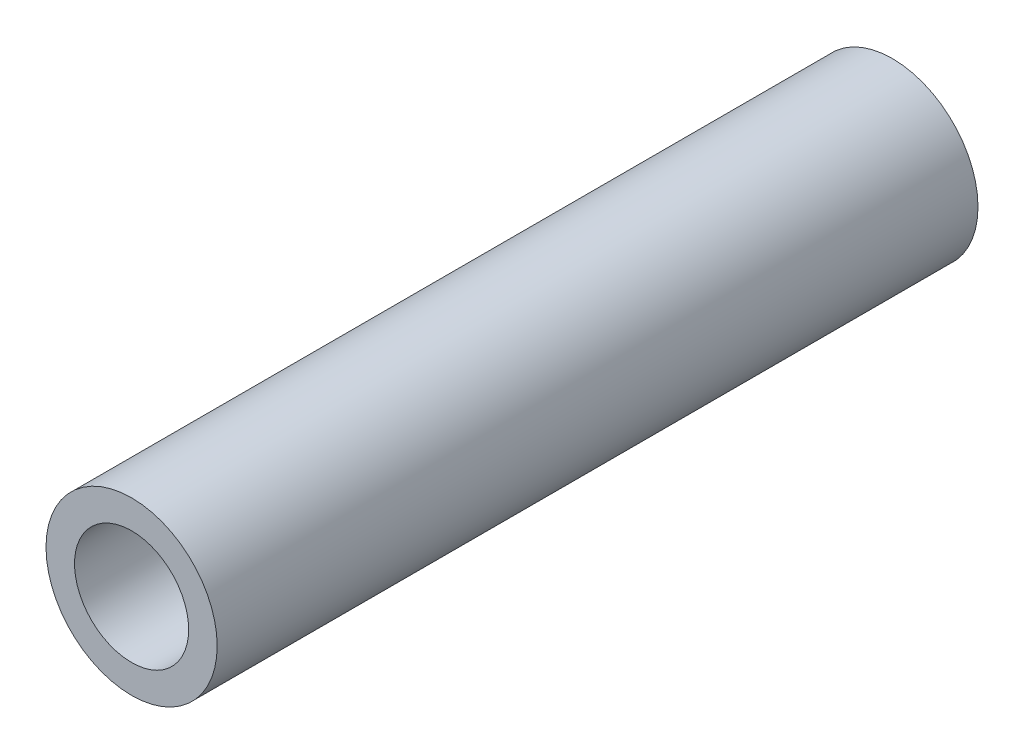
from build123d import *

# Parameters (mm, degrees)
SKETCH1_R   = 9
SKETCH1_R_2 = 6
MAIN_DEPTH  = 80


with BuildPart() as part:
    # Sketch1 → Main (new body)
    with BuildSketch(Plane.XY):
        Circle(SKETCH1_R)
        Circle(SKETCH1_R_2, mode=Mode.SUBTRACT)
    extrude(amount=MAIN_DEPTH)


solid = part.part
